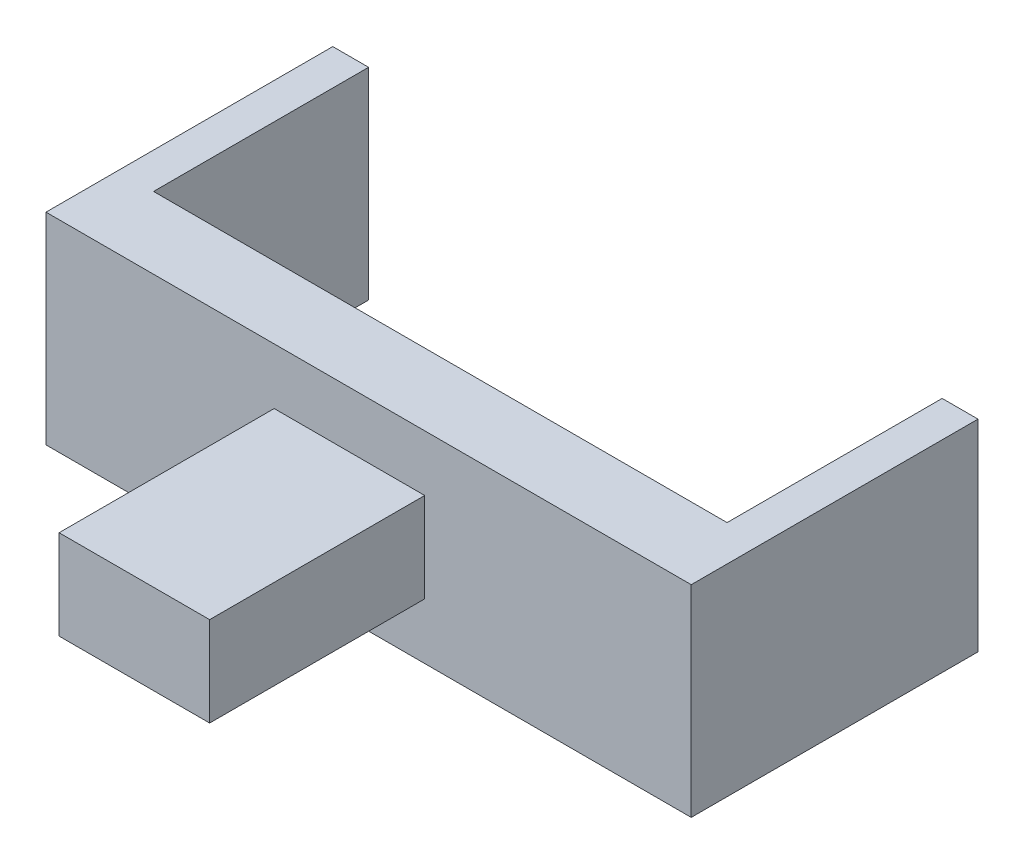
from build123d import *

# Parameters (mm, degrees)
SKETCH_1_W      = 90
SKETCH_1_H      = 28.115702479
EXTRUDE_1_DEPTH = 10
SKETCH_2_W      = 20.999219252
SKETCH_2_H      = 12.492407229
EXTRUDE_2_DEPTH = 30
SKETCH_3_W      = 5
SKETCH_3_H      = 28.115702479
EXTRUDE_3_DEPTH = 30


with BuildPart() as part:
    # 草图1 → 凸台-拉伸1 (new body)
    with BuildSketch(Plane.XY):
        with Locations((2.674645003, 3.474778593)):
            Rectangle(SKETCH_1_W, SKETCH_1_H)
    extrude(amount=EXTRUDE_1_DEPTH)

    # 草图2 → 凸台-拉伸2 (add)
    with BuildSketch(Plane.XY.offset(10)):
        with Locations((0, 3.474778592)):
            Rectangle(SKETCH_2_W, SKETCH_2_H)
    extrude(amount=EXTRUDE_2_DEPTH)

    # 草图3 → 凸台-拉伸3 (add)
    with BuildSketch(Plane(origin=(0, 0, 0), x_dir=(-1, 0, 0), z_dir=(0, 0, -1))):
        with Locations((39.825354997, 3.474778593)):
            Rectangle(SKETCH_3_W, SKETCH_3_H)
        with Locations((-45.174645003, 3.474778593)):
            Rectangle(SKETCH_3_W, SKETCH_3_H)
    extrude(amount=EXTRUDE_3_DEPTH)


solid = part.part
